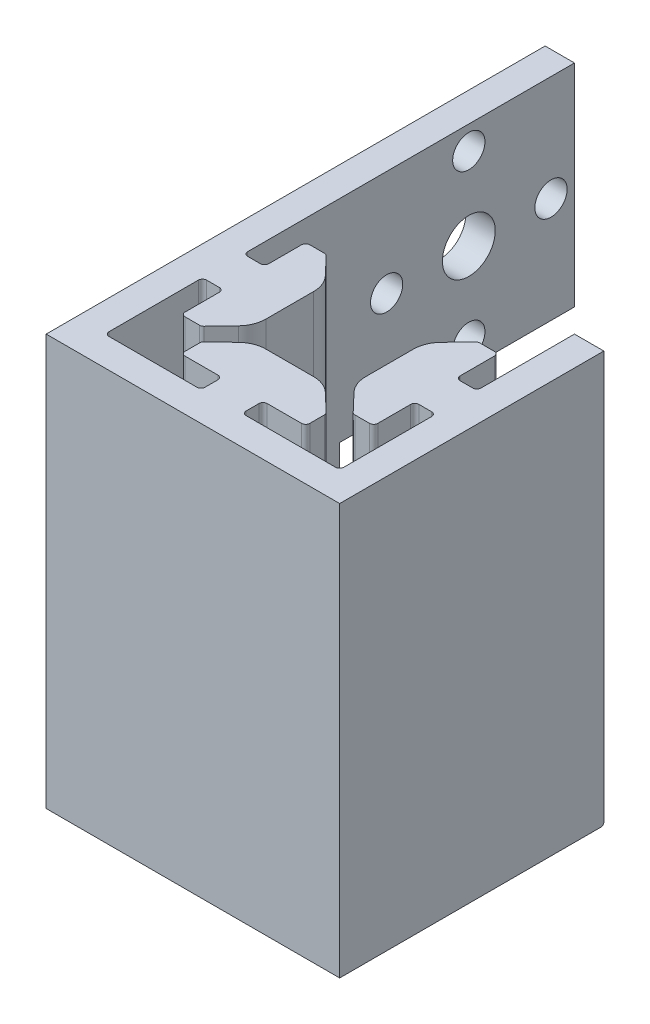
from build123d import *

# Parameters (mm, degrees)
BOSS_EXTRUDE1_DEPTH            = 70
FILLET4_R                      = 0.7
FILLET6_R                      = 4.8
FILLET12_R                     = 0.5
SKETCH2_W                      = 40
SKETCH2_H                      = 36
BOSS_EXTRUDE2_DEPTH            = 5
M5_CLEARANCE_HOLE1_D           = 5.5
M5_CLEARANCE_HOLE1_DEPTH       = 13
M5_CLEARANCE_HOLE1_CSINK_D     = 5.55
M5_CLEARANCE_HOLE1_CSINK_ANGLE = 90
M5_CLEARANCE_HOLE1_TIP         = 1.652366702
SKETCH7_R                      = 4.5
CUT_EXTRUDE1_DEPTH             = 46
CUT_EXTRUDE1_DEPTH_BACK        = 6


with BuildPart() as part:
    # Sketch1 → Boss-Extrude1 (new body)
    with BuildSketch(Plane(origin=(0, 0, 0), x_dir=(1, 0, 0), z_dir=(0, 1, 0))):
        Polygon((-25, -25), (25, -25), (25, 20), (20, 20), (20, 3.375), (16.42, 3.375), (16.42, 10.625), (12.92, 10.625), (8.5, 6), (8.5, -6), (12.92, -10.625), (16.42, -10.625), (16.42, -3.625), (20, -3.625), (20, -20), (3.375, -20), (3.375, -16.42), (10.625, -16.42), (10.625, -12.92), (6, -8.5), (-6, -8.5), (-10.625, -12.92), (-10.625, -16.42), (-3.625, -16.42), (-3.625, -20), (-20, -20), (-20, -3.375), (-16.42, -3.375), (-16.42, -10.625), (-12.92, -10.625), (-8.5, -6), (-8.5, 6), (-12.92, 10.625), (-16.42, 10.625), (-16.42, 3.625), (-20, 3.625), (-20, 20), (-25, 20), align=None)
    extrude(amount=BOSS_EXTRUDE1_DEPTH)

    # Fillet4
    fillet4_edges = [part.edges().sort_by_distance(p)[0] for p in [
        (-3.625, 35, 16.42),
        (-10.625, 35, 16.42),
        (-10.625, 35, 12.92),
        (10.625, 35, 12.92),
        (10.625, 35, 16.42),
        (3.375, 35, 16.42),
        (3.375, 35, 20),
        (20, 35, 20),
        (20, 35, 3.625),
        (16.42, 35, 3.625),
        (16.42, 35, 10.625),
        (12.92, 35, 10.625),
        (12.92, 35, -10.625),
        (16.42, 35, -10.625),
        (16.42, 35, -3.375),
        (20, 35, -3.375),
        (-20, 35, -3.625),
        (-16.42, 35, -3.625),
        (-16.42, 35, -10.625),
        (-12.92, 35, -10.625),
        (-12.92, 35, 10.625),
        (-16.42, 35, 10.625),
        (-16.42, 35, 3.375),
        (-20, 35, 3.375),
        (-20, 35, 20),
        (-3.625, 35, 20),
    ]]
    fillet(fillet4_edges, radius=FILLET4_R)

    # Fillet6
    fillet6_edges = [part.edges().sort_by_distance(p)[0] for p in [
        (-6, 35, 8.5),
        (6, 35, 8.5),
        (8.5, 35, 6),
        (8.5, 35, -6),
        (-8.5, 35, -6),
        (-8.5, 35, 6),
    ]]
    fillet(fillet6_edges, radius=FILLET6_R)

    # Fillet12
    fillet12_edges = [part.edges().sort_by_distance(p)[0] for p in [
        (22.5, 0, -20),
    ]]
    fillet(fillet12_edges, radius=FILLET12_R)

    # Sketch2 → Boss-Extrude2 (add)
    with BuildSketch(Plane.ZY.offset(25)):
        with Locations((-40, 52)):
            Rectangle(SKETCH2_W, SKETCH2_H)
    extrude(amount=-BOSS_EXTRUDE2_DEPTH)

    # M5 Clearance Hole1
    with Locations(Plane.ZY.offset(25)):
        with Locations((-56, 52), (-42, 66), (-28, 52), (-42, 38)):
            CounterSinkHole(M5_CLEARANCE_HOLE1_D / 2, M5_CLEARANCE_HOLE1_CSINK_D / 2, depth=M5_CLEARANCE_HOLE1_DEPTH, counter_sink_angle=M5_CLEARANCE_HOLE1_CSINK_ANGLE)
            with Locations((0, 0, -(M5_CLEARANCE_HOLE1_DEPTH + M5_CLEARANCE_HOLE1_TIP / 2))):  # 118° drill point
                Cone(0, M5_CLEARANCE_HOLE1_D / 2, M5_CLEARANCE_HOLE1_TIP, mode=Mode.SUBTRACT)

    # Sketch7 → Cut-Extrude1 (cut, two sides)
    with BuildSketch(Plane(origin=(-20, 0, 0), x_dir=(0, 0, -1), z_dir=(1, 0, 0))) as cut_extrude1_sk:
        with Locations((42, 52)):
            Circle(SKETCH7_R)
    extrude(amount=CUT_EXTRUDE1_DEPTH, mode=Mode.SUBTRACT)
    extrude(cut_extrude1_sk.sketch, amount=-CUT_EXTRUDE1_DEPTH_BACK, mode=Mode.SUBTRACT)


solid = part.part
